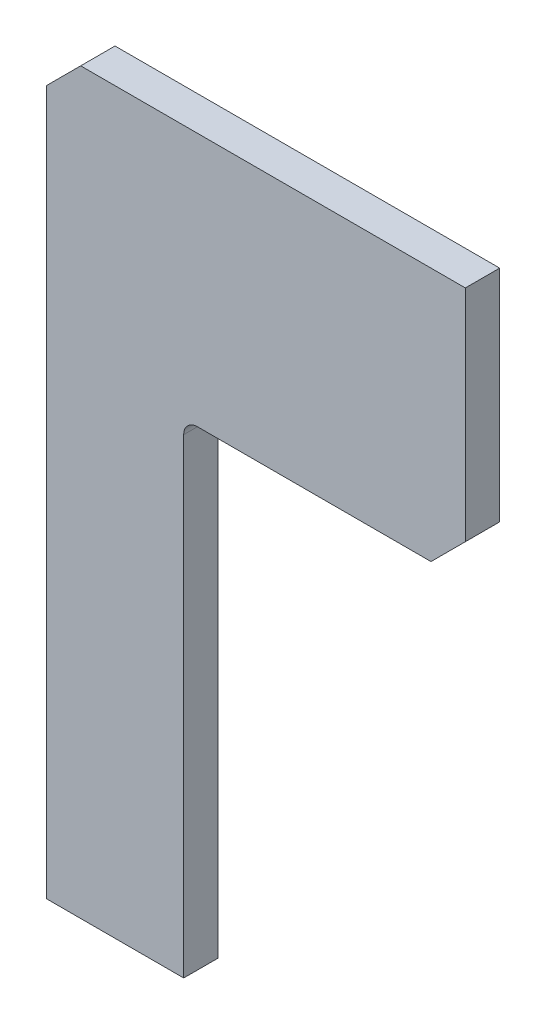
from build123d import *

# Parameters (mm, degrees)
BOSS_EXTRUDE1_DEPTH = 10


with BuildPart() as part:
    # Sketch1 → Boss-Extrude1 (new body)
    with BuildSketch(Plane.XY):
        with BuildLine():
            Line((0, 0), (0, 205))
            Line((0, 205), (10, 215))
            Line((10, 215), (122, 215))
            Line((122, 215), (122, 151))
            Line((122, 151), (112, 141))
            Line((112, 141), (44, 141))
            ThreePointArc((44, 141), (41.171572875, 139.828427125), (40, 137))
            Line((40, 137), (40, 0))
            Line((40, 0), (0, 0))
        make_face()
    extrude(amount=BOSS_EXTRUDE1_DEPTH)


solid = part.part
